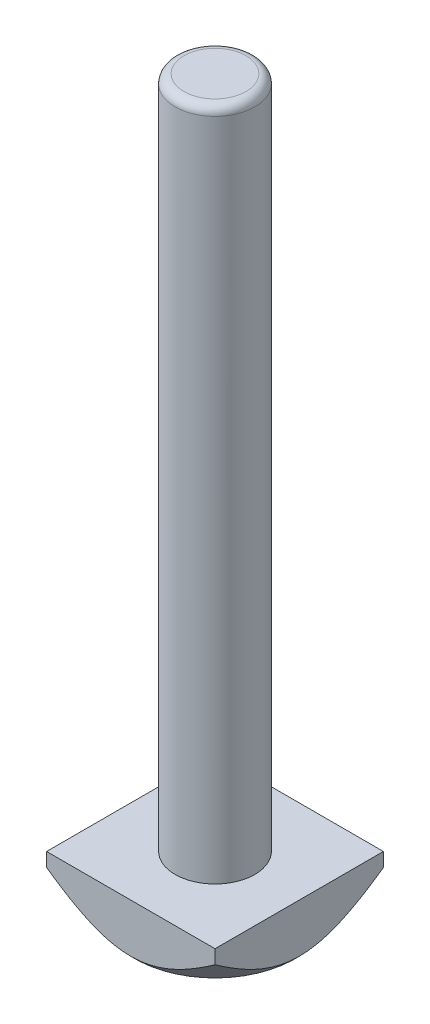
from build123d import *

# Parameters (mm, degrees)
SKETCH1_W           = 19
SKETCH1_H           = 19
BOSS_EXTRUDE1_DEPTH = 6
SKETCH2_R           = 4.5
BOSS_EXTRUDE2_DEPTH = 76
SKETCH3_OUTSIDE_W   = 190.258
SKETCH3_OUTSIDE_H   = 190.258
SKETCH3_OUTSIDE_R   = 9
CUT_EXTRUDE1_DEPTH  = 76
CUT_EXTRUDE1_DRAFT  = -45
FILLET1_R           = 1


with BuildPart() as part:
    # Sketch1 → Boss-Extrude1 (new body)
    with BuildSketch(Plane(origin=(0, 0, 0), x_dir=(1, 0, 0), z_dir=(0, 1, 0))):
        Rectangle(SKETCH1_W, SKETCH1_H)
    extrude(amount=BOSS_EXTRUDE1_DEPTH)

    # Sketch2 → Boss-Extrude2 (add)
    with BuildSketch(Plane(origin=(0, 6, 0), x_dir=(1, 0, 0), z_dir=(0, 1, 0))):
        with Locations(Location((0, 0, 0), (0, 0, 90))):  # turned: the seam where the file's is
            Circle(SKETCH2_R)
    extrude(amount=BOSS_EXTRUDE2_DEPTH)


with BuildPart() as cut_extrude1_tool:
    # Sketch3 outside → Cut-Extrude1 (with draft: the straight prism first)
    with BuildSketch(Plane.XZ):
        Rectangle(SKETCH3_OUTSIDE_W, SKETCH3_OUTSIDE_H)
        Circle(SKETCH3_OUTSIDE_R, mode=Mode.SUBTRACT)
    extrude(amount=-CUT_EXTRUDE1_DEPTH)
    # Cut-Extrude1: the draft: its side faces are tilted about the plane it starts from
    cut_extrude1_sides = [cut_extrude1_tool.faces().sort_by_distance(p)[0] for p in [
        (0, 38, -95.129),
        (95.129, 38, 0),
        (0, 38, 95.129),
        (-95.129, 38, 0),
        (-9, 38, 0),
    ]]
    draft(cut_extrude1_sides, Plane.XZ, CUT_EXTRUDE1_DRAFT)


with BuildPart() as part_1:
    add(part.part)

    # Cut-Extrude1: cut by cut_extrude1_tool
    add(cut_extrude1_tool.part, mode=Mode.SUBTRACT)

    # Fillet1
    fillet1_edges = [part_1.edges().sort_by_distance(p)[0] for p in [
        (0, 82, 4.5),
    ]]
    fillet(fillet1_edges, radius=FILLET1_R)


solid = part_1.part
